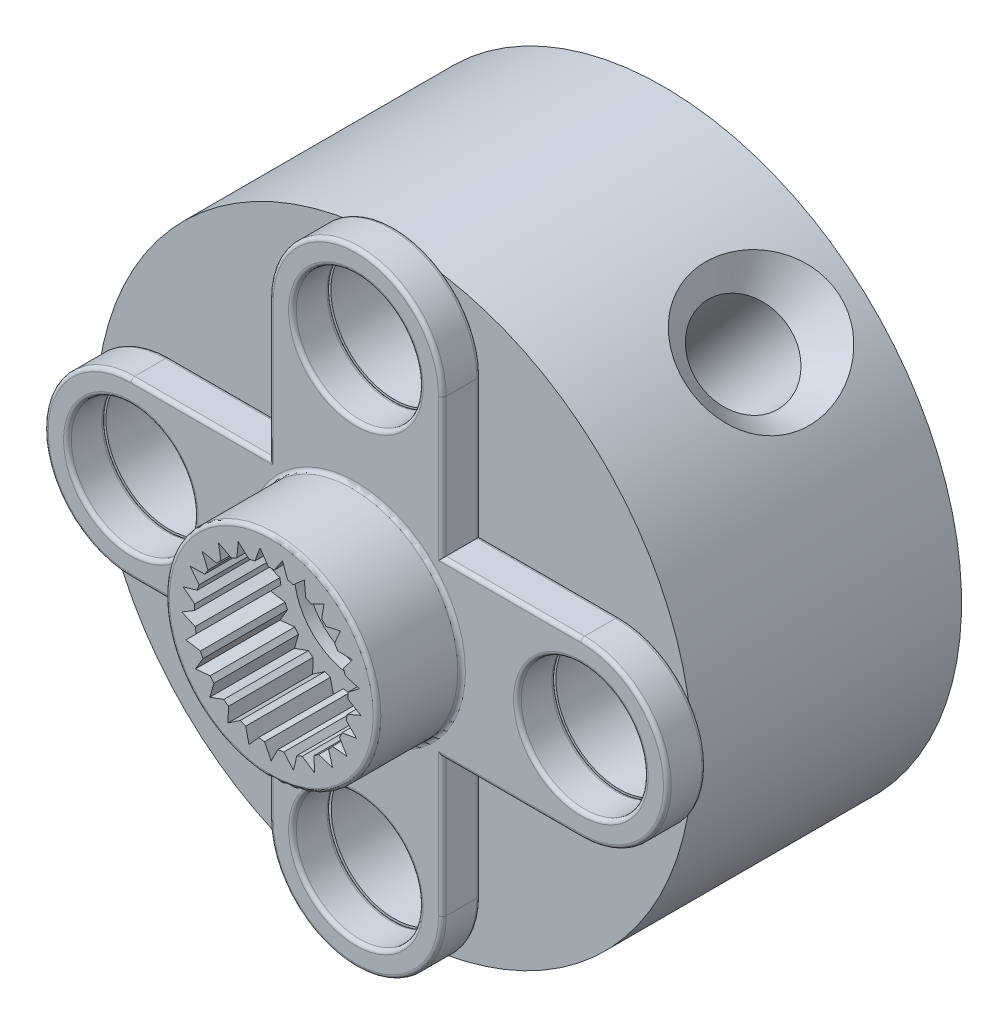
from build123d import *

# Parameters (mm, degrees)
ESQUISSE1_R             = 2.75
BOSS_EXTRU_1_DEPTH      = 1
ESQUISSE2_R             = 2.75
BOSS_EXTRU_2_DEPTH      = 2.2
ESQUISSE3_R             = 2
ENL_V_MAT_EXTRU_1_DEPTH = 2.5
ESQUISSE4_R             = 1.6
ENL_V_MAT_EXTRU_2_DEPTH = 0.4
ESQUISSE5_R             = 0.85
ENL_V_MAT_EXTRU_3_DEPTH = 4.8
ESQUISSE6_R             = 1.65
ENL_V_MAT_EXTRU_4_DEPTH = 4.2
CUT_EXTRUDE1_DEPTH      = 2.5
CIRPATTERN1_COUNT       = 25
BOSS_EXTRUDE1_DEPTH     = 1
SKETCH3_R               = 1.65
CUT_EXTRUDE2_DEPTH      = 4.2
SKETCH5_R               = 1.6
BOSS_EXTRUDE3_DEPTH     = 1
SKETCH9_R               = 1.65
CUT_EXTRUDE6_DEPTH      = 4.2
FILLET5_R               = 0.1
SKETCH11_R              = 7.75
BOSS_EXTRUDE4_DEPTH     = 7
SKETCH12_R              = 3
CUT_EXTRUDE8_DEPTH      = 4
SKETCH21_R              = 1.65
SKETCH21_R_2            = 1.642305881
CUT_EXTRUDE9_DEPTH      = 8.5


with BuildPart() as part:
    # Esquisse1 → Boss.-Extru.1 (new body)
    with BuildSketch(Plane.XY):
        with BuildLine():
            ThreePointArc((2.25, 5.85), (0, 8.1), (-2.25, 5.85))
            Line((-2.25, 5.85), (-2.25, 1.58113883))
            ThreePointArc((-2.25, 1.58113883), (0, 2.75), (2.25, 1.58113883))
            Line((2.25, 1.58113883), (2.25, 5.85))
        make_face()
        Circle(ESQUISSE1_R)
    extrude(amount=BOSS_EXTRU_1_DEPTH)

    # Esquisse2 → Boss.-Extru.2 (add)
    with BuildSketch(Plane.XY.offset(1)):
        Circle(ESQUISSE2_R)
    extrude(amount=BOSS_EXTRU_2_DEPTH)

    # Esquisse3 → Enlèv. mat.-Extru.1 (cut)
    with BuildSketch(Plane.XY.offset(3.2)):
        Circle(ESQUISSE3_R)
    extrude(amount=-ENL_V_MAT_EXTRU_1_DEPTH, mode=Mode.SUBTRACT)

    # Esquisse4 → Enlèv. mat.-Extru.2 (cut)
    with BuildSketch(Plane(origin=(0, 0, 0), x_dir=(-1, 0, 0), z_dir=(0, 0, -1))):
        Circle(ESQUISSE4_R)
    extrude(amount=-ENL_V_MAT_EXTRU_2_DEPTH, mode=Mode.SUBTRACT)

    # Esquisse5 → Enlèv. mat.-Extru.3 (cut)
    with BuildSketch(Plane(origin=(0, 0, 0.4), x_dir=(-1, 0, 0), z_dir=(0, 0, -1))):
        Circle(ESQUISSE5_R)
    extrude(amount=-ENL_V_MAT_EXTRU_3_DEPTH, mode=Mode.SUBTRACT)

    # Esquisse6 → Enlèv. mat.-Extru.4 (cut, through all)
    with BuildSketch(Plane(origin=(0, 0, 0), x_dir=(-1, 0, 0), z_dir=(0, 0, -1))):
        with Locations((0, 5.85)):
            Circle(ESQUISSE6_R)
    extrude(amount=-ENL_V_MAT_EXTRU_4_DEPTH, mode=Mode.SUBTRACT)

    # Sketch1 → Cut-Extrude1 (cut)
    with BuildSketch(Plane.XY.offset(3.2)):
        with BuildLine():
            Line((0.174311485, -1.992389396), (0, -2.334))
            Line((0, -2.334), (-0.174311485, -1.992389396))
            ThreePointArc((-0.174311485, -1.992389396), (0, -2), (0.174311485, -1.992389396))
        make_face()
    cut_extrude1 = extrude(amount=-CUT_EXTRUDE1_DEPTH, mode=Mode.SUBTRACT)

    # CirPattern1: Cut-Extrude1 ×25 about axis
    cirpattern1_axis = Axis((0, 0, 0), (0, 0, 1))
    for i in range(1, CIRPATTERN1_COUNT):
        add(cut_extrude1.rotate(cirpattern1_axis, i * 360 / CIRPATTERN1_COUNT), mode=Mode.SUBTRACT)

    # Sketch2 → Boss-Extrude1 (add)
    with BuildSketch(Plane(origin=(0, 0, 0), x_dir=(-1, 0, 0), z_dir=(0, 0, -1))):
        with BuildLine():
            Line((2.25, -1.58113883), (2.25, -5.85))
            ThreePointArc((2.25, -5.85), (0, -8.1), (-2.25, -5.85))
            Line((-2.25, -5.85), (-2.25, -1.58113883))
            ThreePointArc((-2.25, -1.58113883), (0, -2.75), (2.25, -1.58113883))
        make_face()
    extrude(amount=-BOSS_EXTRUDE1_DEPTH)

    # Sketch3 → Cut-Extrude2 (cut, through all)
    with BuildSketch(Plane(origin=(0, 0, 0), x_dir=(-1, 0, 0), z_dir=(0, 0, -1))):
        with Locations((0, -5.85)):
            Circle(SKETCH3_R)
    extrude(amount=-CUT_EXTRUDE2_DEPTH, mode=Mode.SUBTRACT)

    # Sketch5 → Boss-Extrude3 (add)
    with BuildSketch(Plane(origin=(0, 0, 0), x_dir=(-1, 0, 0), z_dir=(0, 0, -1))):
        with BuildLine():
            Line((5.85, 2.25), (-5.85, 2.25))
            ThreePointArc((-5.85, 2.25), (-8.1, 0), (-5.85, -2.25))
            Line((-5.85, -2.25), (5.85, -2.25))
            ThreePointArc((5.85, -2.25), (8.1, 0), (5.85, 2.25))
        make_face()
        Circle(SKETCH5_R, mode=Mode.SUBTRACT)
    extrude(amount=-BOSS_EXTRUDE3_DEPTH)

    # Sketch9 → Cut-Extrude6 (cut, through all)
    with BuildSketch(Plane(origin=(0, 0, 0), x_dir=(-1, 0, 0), z_dir=(0, 0, -1))):
        with Locations((5.85, 0)):
            Circle(SKETCH9_R)
        with Locations((-5.85, 0)):
            Circle(SKETCH9_R)
    extrude(amount=-CUT_EXTRUDE6_DEPTH, mode=Mode.SUBTRACT)

    # Fillet5
    fillet5_edges = [part.edges().sort_by_distance(p)[0] for p in [
        (-2.25, 4.05, 1),
        (-2.75, 0, 1),
        (-2.75, 0, 3.2),
        (1.6, 0, 0),
        (0, -8.1, 1),
        (0, -8.1, 0),
        (1.65, -5.85, 1),
        (1.65, -5.85, 0),
        (-2.25, -4.05, 1),
        (-2.25, -4.05, 0),
        (2.25, -4.05, 1),
        (2.25, -4.05, 0),
        (1.65, 5.85, 1),
        (1.65, 5.85, 0),
        (-4.05, 2.25, 1),
        (4.05, 2.25, 1),
        (-4.05, -2.25, 1),
        (-4.05, 2.25, 0),
        (-4.05, -2.25, 0),
        (-8.1, 0, 0),
        (-8.1, 0, 1),
        (4.05, -2.25, 1),
        (8.1, 0, 1),
        (2.25, 4.05, 1),
        (4.05, 2.25, 0),
        (8.1, 0, 0),
        (4.05, -2.25, 0),
        (-4.2, 0, 1),
        (-4.2, 0, 0),
        (7.5, 0, 1),
        (7.5, 0, 0),
        (-2.25, 4.05, 0),
        (0, 8.1, 0),
        (2.25, 4.05, 0),
        (0, 8.1, 1),
    ]]
    fillet(fillet5_edges, radius=FILLET5_R)


with BuildPart() as body_2:
    # Sketch11 → Boss-Extrude4 (new body)
    with BuildSketch(Plane(origin=(0, 0, 0), x_dir=(-1, 0, 0), z_dir=(0, 0, -1))):
        Circle(SKETCH11_R)
    extrude(amount=BOSS_EXTRUDE4_DEPTH)

    # Sketch12 → Cut-Extrude8 (cut)
    with BuildSketch(Plane(origin=(0, 0, -7), x_dir=(-1, 0, 0), z_dir=(0, 0, -1))):
        Circle(SKETCH12_R)
    extrude(amount=-CUT_EXTRUDE8_DEPTH, mode=Mode.SUBTRACT)

    # Sketch21 → Cut-Extrude9 (cut)
    with BuildSketch(Plane.XY):
        with Locations((0, 5.85)):
            Circle(SKETCH21_R)
        with Locations((5.85, 0)):
            Circle(SKETCH21_R)
        with Locations((-5.85, 0)):
            Circle(SKETCH21_R)
        with Locations((0, -5.85)):
            Circle(SKETCH21_R_2)
    extrude(amount=-CUT_EXTRUDE9_DEPTH, mode=Mode.SUBTRACT)

    # Sketch32 → CSK for M2 Cross Countersunk Head Screw2 (revolve, cut)
    with BuildSketch(Plane(origin=(5.086883915, 5.846889091, -4.491649317), x_dir=(-0.754437302, 0.656372118, 0), z_dir=(0, 0, 1))):
        Polygon((0, 0), (0, 7.75), (1.2, 7.75), (1.2, 0.77255102), (2, 0), align=None)
    revolve(axis=Axis((9.254846864, 10.637565958, -4.491649317), (-0.656372118, -0.754437302, 0)), mode=Mode.SUBTRACT)


solid = Compound([part.part, body_2.part])
